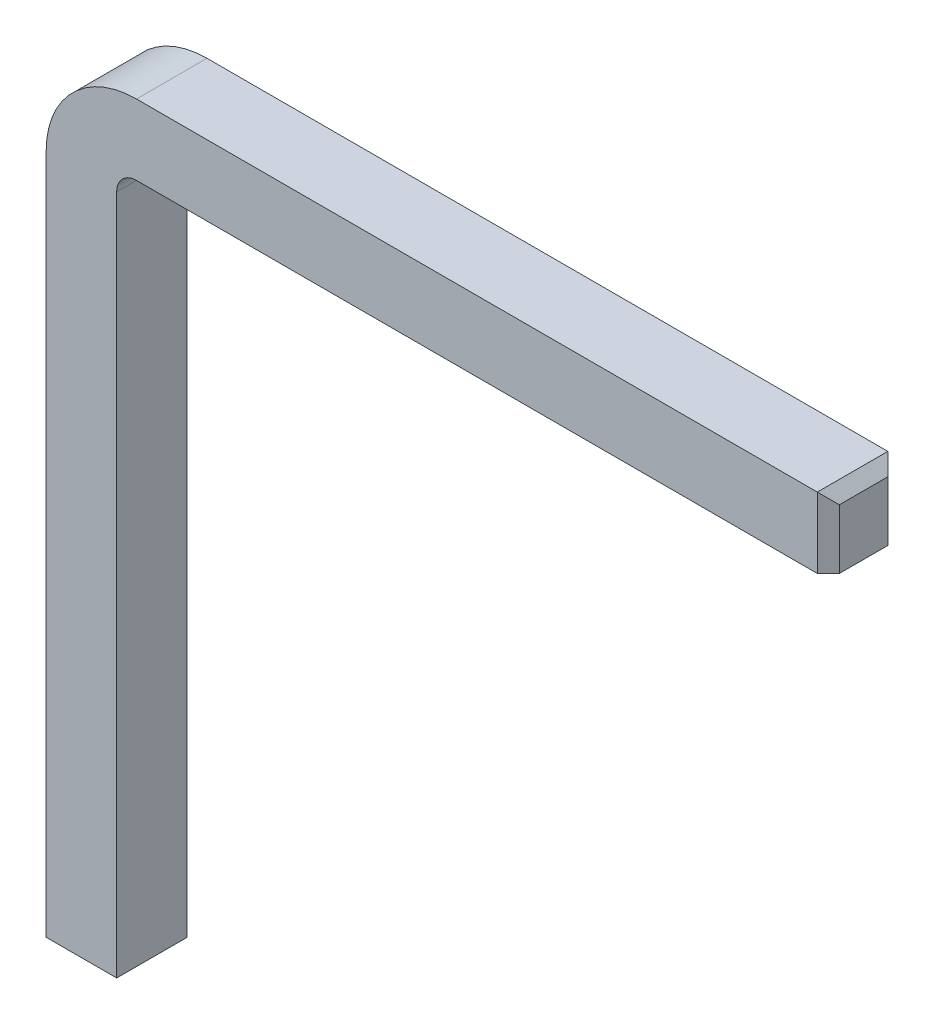
from build123d import *

# Parameters (mm, degrees)
SKETCH_1_W     = 0.64
SKETCH_1_H     = 0.64
CHAMFER_1_SIZE = 0.1


with BuildPart() as part:
    # По траектории1: sweep along a path in Эскиз2
    with BuildLine(Plane.XY) as sweep_1_path:
        Line((0, 0), (0, 6.28))
        ThreePointArc((0, 6.28), (0.146446609, 6.633553391), (0.5, 6.78))
        Line((0.5, 6.78), (6.78, 6.78))
    # Эскиз1 → По траектории1 (sweep)
    with BuildSketch(Plane(origin=(0, 0, 0), x_dir=(1, 0, 0), z_dir=(0, 1, 0))):
        Rectangle(SKETCH_1_W, SKETCH_1_H)
    sweep(path=sweep_1_path.line)

    # Фаска1
    chamfer_1_edges = [part.edges().sort_by_distance(p)[0] for p in [
        (6.78, 6.78, 0.32),
        (6.78, 7.1, 0),
        (6.78, 6.78, -0.32),
        (0, 0, 0.32),
        (-0.32, 0, 0),
        (0, 0, -0.32),
        (0.32, 0, 0),
    ]]
    chamfer(chamfer_1_edges, length=CHAMFER_1_SIZE)


solid = part.part
